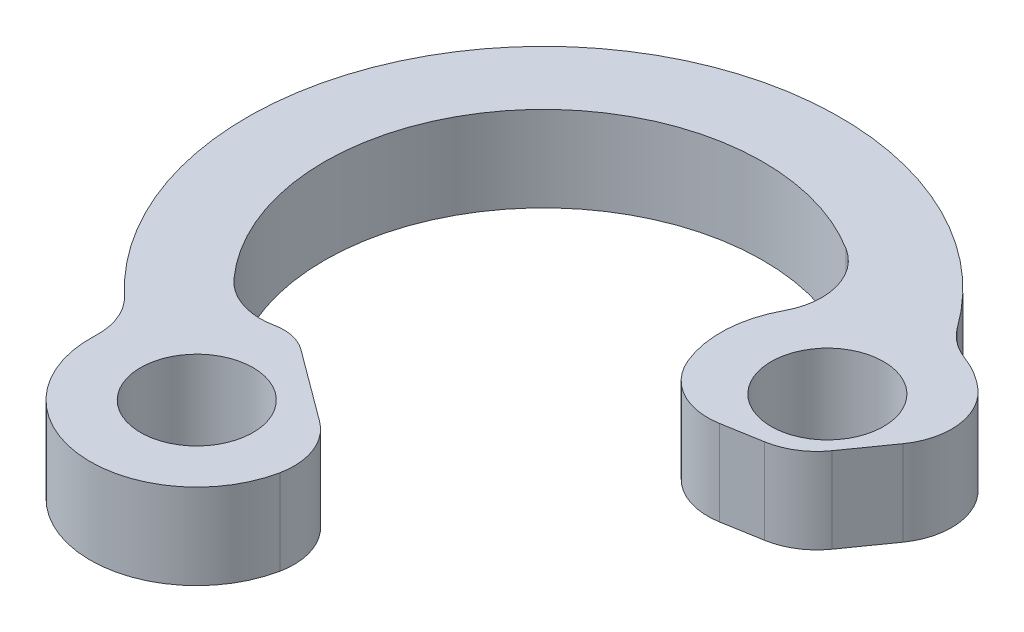
from build123d import *

# Parameters (mm, degrees)
SKETCH1_R           = 2.6375
BOSS_EXTRUDE1_DEPTH = 4


with BuildPart() as part:
    # Sketch1 → Boss-Extrude1 (new body)
    with BuildSketch(Plane(origin=(0, 4, 0), x_dir=(1, 0, 0), z_dir=(0, 1, 0))):
        with BuildLine():
            Line((85.735483712, 77.323980784), (87.547228424, 77.6361992))
            ThreePointArc((87.547228424, 77.6361992), (88.638512401, 78.055387782), (89.486725608, 78.859846695))
            Line((89.486725608, 78.859846695), (90.859907816, 80.800603382))
            ThreePointArc((90.859907816, 80.800603382), (91.392372444, 82.866543385), (90.417013283, 84.763989347))
            ThreePointArc((90.417013283, 84.763989347), (89.660091993, 85.325292733), (88.8112973, 85.73460789))
            ThreePointArc((88.8112973, 85.73460789), (88.035402119, 86.161615284), (87.417993221, 86.796560083))
            ThreePointArc((87.417993221, 86.796560083), (66.977031359, 89.139944323), (66.603972706, 68.568478678))
            ThreePointArc((66.603972706, 68.568478678), (67.327519051, 67.51101449), (67.543844855, 66.248100016))
            ThreePointArc((67.543844855, 66.248100016), (71.92413831, 61.058265048), (77.438126505, 65.022769043))
            ThreePointArc((77.438126505, 65.022769043), (77.298986696, 66.69694337), (76.281652818, 68.033824571))
            Line((76.281652818, 68.033824571), (72.915652336, 70.521815026))
            ThreePointArc((72.915652336, 70.521815026), (72.158360379, 70.866374525), (71.326393596, 70.872979652))
            ThreePointArc((71.326393596, 70.872979652), (69.787994238, 70.962547772), (68.497017033, 71.804018441))
            ThreePointArc((68.497017033, 71.804018441), (68.277664092, 85.314017723), (81.632240885, 87.369127207))
            ThreePointArc((81.632240885, 87.369127207), (82.929152896, 85.595651679), (82.669646853, 83.413942984))
            ThreePointArc((82.669646853, 83.413942984), (82.079827473, 81.296958117), (82.454695982, 79.131551589))
            ThreePointArc((82.454695982, 79.131551589), (83.778317702, 77.652816556), (85.735483712, 77.323980784))
        make_face()
        with Locations((72.538655529, 66.020358214)):
            Circle(SKETCH1_R, mode=Mode.SUBTRACT)
        with Locations((87.073540725, 81.04630307)):
            Circle(SKETCH1_R, mode=Mode.SUBTRACT)
    extrude(amount=-BOSS_EXTRUDE1_DEPTH)


solid = part.part
